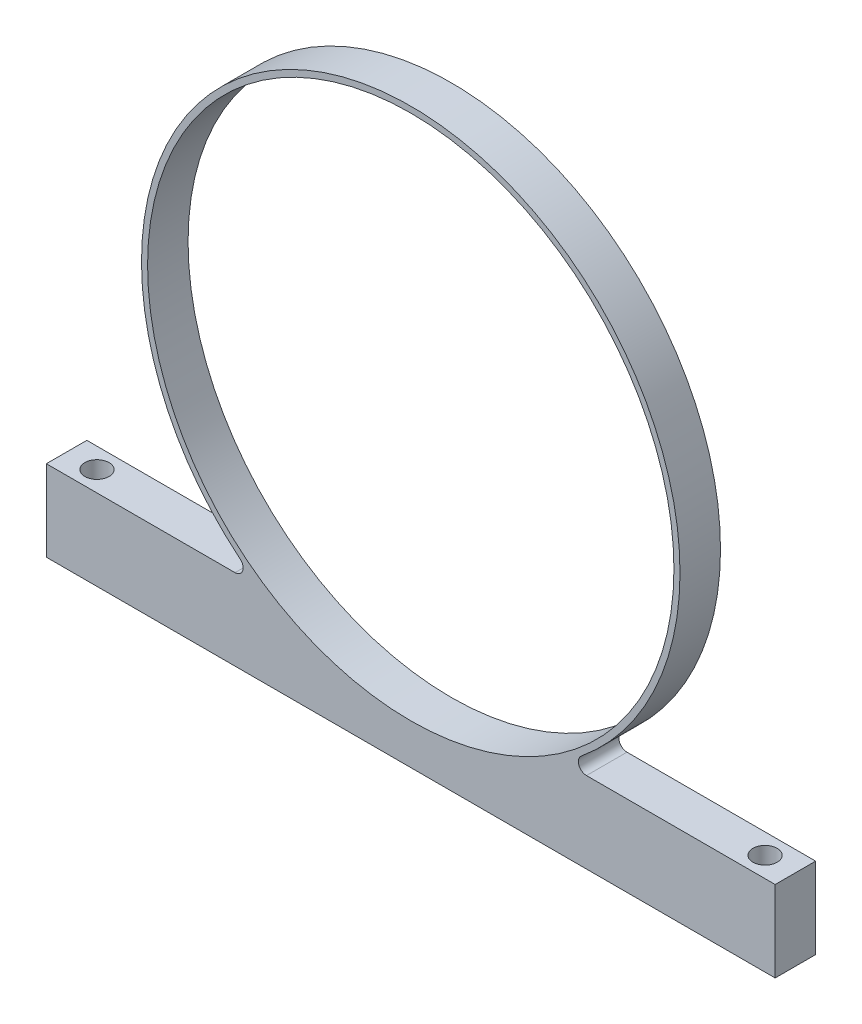
from build123d import *

# Parameters (mm, degrees)
SKETCH1_R                 = 41.275
BOSS_EXTRUDE1_DEPTH       = 6.35
FILLET1_R                 = 1.27
F_6_CLEARANCE_HOLE1_D     = 3.7973
F_6_CLEARANCE_HOLE1_DEPTH = 25.4
F_6_CLEARANCE_HOLE1_TIP   = 1.140824014


with BuildPart() as part:
    # Sketch1 → Boss-Extrude1 (new body)
    with BuildSketch(Plane.XY):
        with BuildLine():
            Line((-23.736177688, -34.925), (-57.15, -34.925))
            Line((-57.15, -34.925), (-57.15, -47.625))
            Line((-57.15, -47.625), (57.15, -47.625))
            Line((57.15, -47.625), (57.15, -34.925))
            Line((57.15, -34.925), (23.736177688, -34.925))
            ThreePointArc((23.736177688, -34.925), (0, 42.2275), (-23.736177688, -34.925))
        make_face()
        Circle(SKETCH1_R, mode=Mode.SUBTRACT)
    extrude(amount=BOSS_EXTRUDE1_DEPTH)

    # Fillet1
    fillet1_edges = [part.edges().sort_by_distance(p)[0] for p in [
        (-23.736177688, -34.925, 3.175),
        (23.736177688, -34.925, 3.175),
    ]]
    fillet(fillet1_edges, radius=FILLET1_R)

    # #6 Clearance Hole1
    with Locations(Plane.XZ.offset(47.625)):
        with Locations((-52.3875, 3.175), (52.3875, 3.175)):
            Hole(F_6_CLEARANCE_HOLE1_D / 2, depth=F_6_CLEARANCE_HOLE1_DEPTH)
            with Locations((0, 0, -(F_6_CLEARANCE_HOLE1_DEPTH + F_6_CLEARANCE_HOLE1_TIP / 2))):  # 118° drill point
                Cone(0, F_6_CLEARANCE_HOLE1_D / 2, F_6_CLEARANCE_HOLE1_TIP, mode=Mode.SUBTRACT)


solid = part.part
